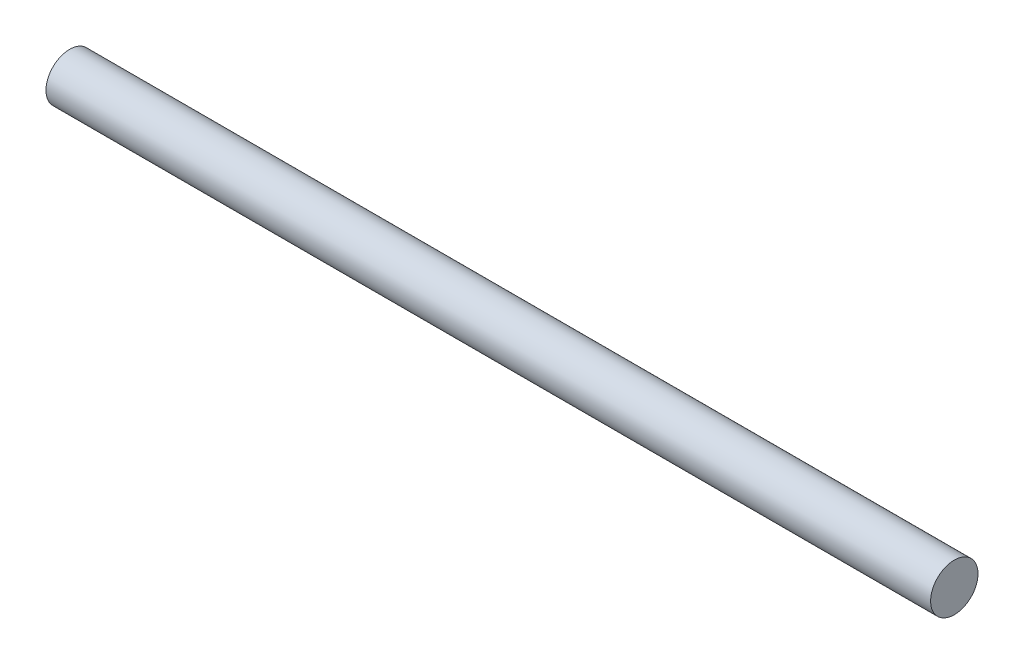
from build123d import *

# Parameters (mm, degrees)
SKETCH2_R           = 15
BOSS_EXTRUDE1_DEPTH = 560


with BuildPart() as part:
    # Sketch2 → Boss-Extrude1 (new body)
    with BuildSketch(Plane(origin=(0, 0, 0), x_dir=(0, 0, -1), z_dir=(1, 0, 0))):
        Circle(SKETCH2_R)
    extrude(amount=BOSS_EXTRUDE1_DEPTH)


solid = part.part
